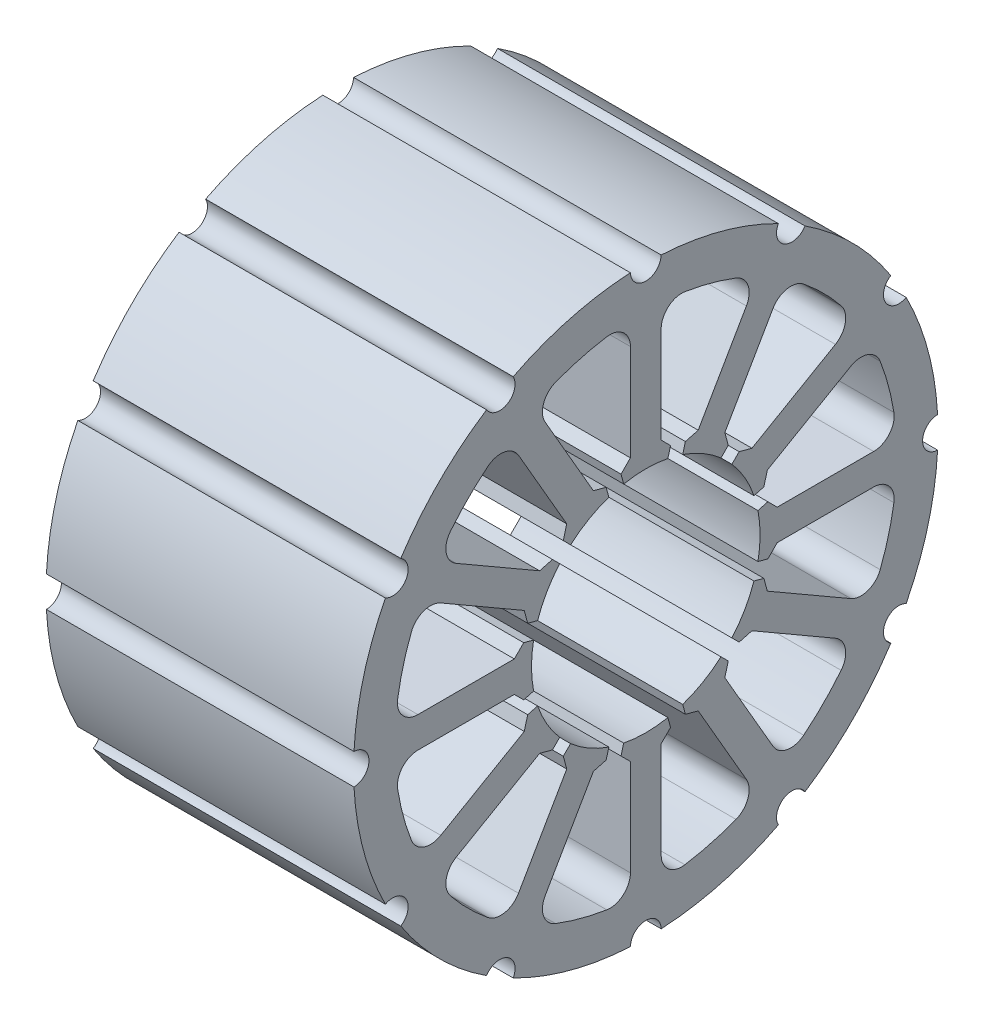
from build123d import *

# Parameters (mm, degrees)
BOSS_EXTRUDE1_DEPTH = 30
CIRPATTERN1_COUNT   = 12
SKETCH4_R           = 1.5
CUT_EXTRUDE1_DEPTH  = 30
CIRPATTERN2_COUNT   = 12


with BuildPart() as part:
    # Sketch3 → Boss-Extrude1 (new body)
    with BuildSketch(Plane(origin=(0, 0, 0), x_dir=(0, 0, -1), z_dir=(1, 0, 0))):
        with BuildLine():
            Line((-14.25, 24.681724008), (-5.575, 9.656183252))
            ThreePointArc((-5.575, 9.656183252), (-4.611154785, 10.151834886), (-3.603740814, 10.551566336))
            Line((-3.603740814, 10.551566336), (-3.863098868, 11.519503771))
            Line((-3.863098868, 11.519503771), (-5.111933128, 11.854127903))
            Line((-5.111933128, 11.854127903), (-9.81401728, 19.998376555))
            ThreePointArc((-9.81401728, 19.998376555), (-9.96754629, 21.665151442), (-8.800363492, 22.864898915))
            ThreePointArc((-8.800363492, 22.864898915), (-6.341066605, 23.665182744), (-3.811111111, 24.201765062))
            ThreePointArc((-3.811111111, 24.201765062), (-2.200427421, 23.746344671), (-1.5, 22.226110771))
            Line((-1.5, 22.226110771), (-1.5, 12.821942467))
            Line((-1.5, 12.821942467), (-2.414210129, 11.907732339))
            Line((-2.414210129, 11.907732339), (-2.154852075, 10.939794904))
            ThreePointArc((-2.154852075, 10.939794904), (-1.082540259, 11.097324299), (0, 11.15))
            Line((0, 11.15), (0, 28.5))
            ThreePointArc((0, 28.5), (-7.376342785, 27.528886049), (-14.25, 24.681724008))
        make_face()
    boss_extrude1 = extrude(amount=BOSS_EXTRUDE1_DEPTH)

    # CirPattern1: Boss-Extrude1 ×12 about axis
    cirpattern1_axis = Axis((-2, 0, 0), (1, 0, 0))
    for i in range(1, CIRPATTERN1_COUNT):
        add(boss_extrude1.rotate(cirpattern1_axis, i * 360 / CIRPATTERN1_COUNT))

    # Sketch4 → Cut-Extrude1 (cut)
    with BuildSketch(Plane(origin=(0, 0, 0), x_dir=(0, 0, -1), z_dir=(1, 0, 0))):
        with Locations((0, 28.5)):
            Circle(SKETCH4_R)
    cut_extrude1 = extrude(amount=CUT_EXTRUDE1_DEPTH, mode=Mode.SUBTRACT)

    # CirPattern2: Cut-Extrude1 ×12 about axis
    cirpattern2_axis = Axis((-2, 0, 0), (1, 0, 0))
    for i in range(1, CIRPATTERN2_COUNT):
        add(cut_extrude1.rotate(cirpattern2_axis, i * 360 / CIRPATTERN2_COUNT), mode=Mode.SUBTRACT)


solid = part.part
